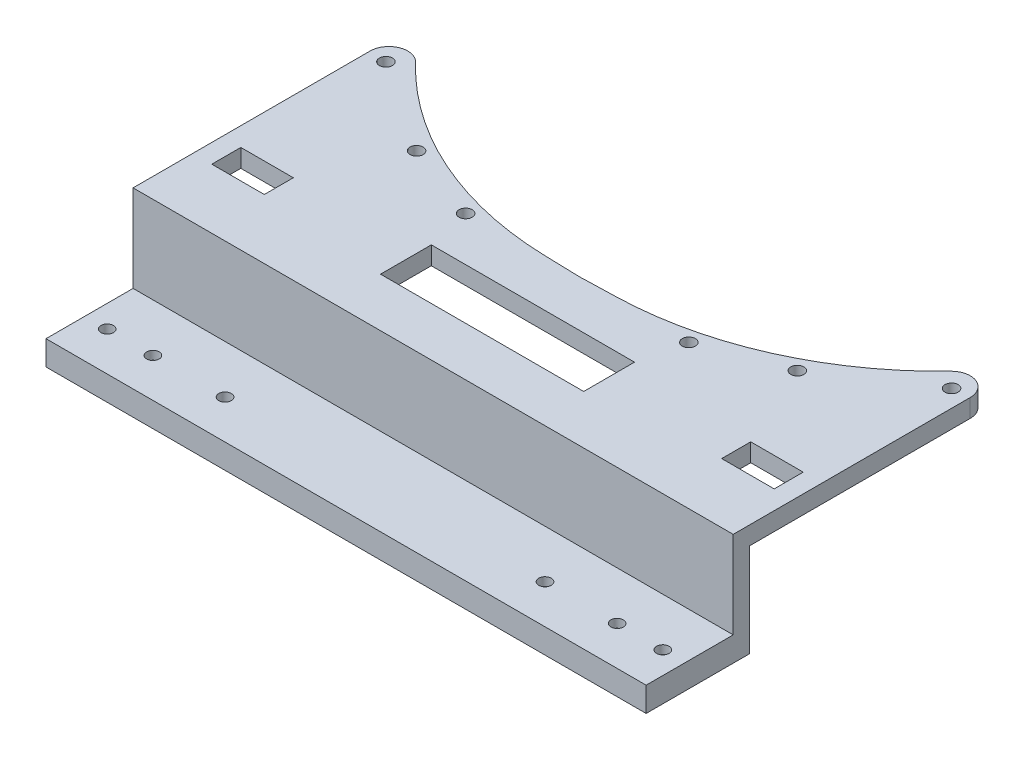
from build123d import *

# Parameters (mm, degrees)
BOSS_EXTRUDE2_DEPTH = 14.285
SKETCH4_W           = 105.034
SKETCH4_H           = 3.81
BOSS_EXTRUDE3_DEPTH = 19.533
SKETCH5_W           = 15.24
SKETCH5_H           = 15.24
CUT_EXTRUDE1_DEPTH  = 105.034
BOSS_EXTRUDE7_START = -3.175
BOSS_EXTRUDE7_DEPTH = 3.175
CUT_EXTRUDE2_REACH  = 21.533
SKETCH9_R           = 1.15
SKETCH9_W           = 35.56
SKETCH9_H           = 8.89
SKETCH9_W_2         = 9.19
SKETCH9_H_2         = 5.08
CUT_EXTRUDE3_REACH  = 6.293
SKETCH13_R          = 1.0922


with BuildPart() as part:
    # Sketch1 → Boss-Extrude2 (new body)
    with BuildSketch(Plane.XY):
        Polygon((13.381, 0.381), (-0.381, 0.381), (-0.381, -1.397), (0.4572, -1.397), (0.4572, -2.413), (-1.397, -2.413), (-1.397, 1.397), (-1.397, 17.12), (103.637, 17.12), (103.637, 1.397), (103.637, -2.413), (101.7828, -2.413), (101.7828, -1.397), (102.621, -1.397), (102.621, 0.381), (88.859, 0.381), (88.859, -1.397), (89.621, -1.397), (89.621, -2.413), (87.843, -2.413), (83.017, -2.413), (81.1628, -2.413), (81.1628, -1.397), (82.001, -1.397), (82.001, 0.381), (20.239, 0.381), (20.239, -1.397), (21.0772, -1.397), (21.0772, -2.413), (19.223, -2.413), (14.397, -2.413), (12.619, -2.413), (12.619, -1.397), (13.381, -1.397), align=None)
    extrude(amount=-BOSS_EXTRUDE2_DEPTH)

    # Sketch4 → Boss-Extrude3 (add)
    with BuildSketch(Plane(origin=(0, 17.12, 0), x_dir=(1, 0, 0), z_dir=(0, 1, 0))):
        with Locations((51.12, -1.905)):
            Rectangle(SKETCH4_W, SKETCH4_H)
    extrude(amount=-BOSS_EXTRUDE3_DEPTH)

    # Sketch5 → Cut-Extrude1 (cut)
    with BuildSketch(Plane(origin=(103.637, 0, 0), x_dir=(0, 0, -1), z_dir=(1, 0, 0))):
        with Locations((3.81, 9.5)):
            Rectangle(SKETCH5_W, SKETCH5_H)
    extrude(amount=-CUT_EXTRUDE1_DEPTH, mode=Mode.SUBTRACT)

    # Sketch8 → Boss-Extrude7 (add)
    with BuildSketch(Plane(origin=(0, 17.12, 0), x_dir=(1, 0, 0), z_dir=(0, 1, 0)).offset(BOSS_EXTRUDE7_START)):
        with BuildLine():
            Line((-1.397, 52.90899931), (-1.397, 14.285))
            Line((-1.397, 14.285), (103.637, 14.285))
            Line((103.637, 14.285), (103.637, 52.90899931))
            ThreePointArc((103.637, 52.90899931), (101.565258526, 55.97325582), (97.949738971, 55.192359514))
            ThreePointArc((97.949738971, 55.192359514), (79.465238701, 42.200806947), (57.433563247, 37.194564339))
            Line((57.433563247, 37.194564339), (51.12, 37.012430992))
            Line((51.12, 37.012430992), (44.806436753, 37.194564339))
            ThreePointArc((44.806436753, 37.194564339), (22.774761299, 42.200806947), (4.290261029, 55.192359514))
            ThreePointArc((4.290261029, 55.192359514), (0.674741474, 55.97325582), (-1.397, 52.90899931))
        make_face()
    extrude(amount=BOSS_EXTRUDE7_DEPTH)

    # Sketch9 → Cut-Extrude2 (cut, up to next)
    with BuildSketch(Plane(origin=(0, 17.12, 0), x_dir=(1, 0, 0), z_dir=(0, 1, 0)), mode=Mode.PRIVATE) as cut_extrude2_sk1:
        with Locations((100.617474683, 52.660280557)):
            Circle(SKETCH9_R)
    cut_extrude2_tool1 = extrude(cut_extrude2_sk1.sketch, amount=-CUT_EXTRUDE2_REACH, mode=Mode.PRIVATE) & part.part
    add(cut_extrude2_tool1.solids().sort_by_distance((100.617475, 17.12, -52.660281))[0], mode=Mode.SUBTRACT)
    # Sketch9 → Cut-Extrude2 (cut, up to next)
    with BuildSketch(Plane(origin=(0, 17.12, 0), x_dir=(1, 0, 0), z_dir=(0, 1, 0)), mode=Mode.PRIVATE) as cut_extrude2_sk2:
        with Locations((84.44065509, 41.851275276)):
            Circle(SKETCH9_R)
    cut_extrude2_tool2 = extrude(cut_extrude2_sk2.sketch, amount=-CUT_EXTRUDE2_REACH, mode=Mode.PRIVATE) & part.part
    add(cut_extrude2_tool2.solids().sort_by_distance((84.440655, 17.12, -41.851275))[0], mode=Mode.SUBTRACT)
    # Sketch9 → Cut-Extrude2 (cut, up to next)
    with BuildSketch(Plane(origin=(0, 17.12, 0), x_dir=(1, 0, 0), z_dir=(0, 1, 0)), mode=Mode.PRIVATE) as cut_extrude2_sk3:
        with Locations((70.655700553, 36.645378632)):
            Circle(SKETCH9_R)
    cut_extrude2_tool3 = extrude(cut_extrude2_sk3.sketch, amount=-CUT_EXTRUDE2_REACH, mode=Mode.PRIVATE) & part.part
    add(cut_extrude2_tool3.solids().sort_by_distance((70.655701, 17.12, -36.645379))[0], mode=Mode.SUBTRACT)
    # Sketch9 → Cut-Extrude2 (cut, up to next)
    with BuildSketch(Plane(origin=(0, 17.12, 0), x_dir=(1, 0, 0), z_dir=(0, 1, 0)), mode=Mode.PRIVATE) as cut_extrude2_sk4:
        with Locations((31.584299447, 36.645378632)):
            Circle(SKETCH9_R)
    cut_extrude2_tool4 = extrude(cut_extrude2_sk4.sketch, amount=-CUT_EXTRUDE2_REACH, mode=Mode.PRIVATE) & part.part
    add(cut_extrude2_tool4.solids().sort_by_distance((31.584299, 17.12, -36.645379))[0], mode=Mode.SUBTRACT)
    # Sketch9 → Cut-Extrude2 (cut, up to next)
    with BuildSketch(Plane(origin=(0, 17.12, 0), x_dir=(1, 0, 0), z_dir=(0, 1, 0)), mode=Mode.PRIVATE) as cut_extrude2_sk5:
        with Locations((17.79934491, 41.851275276)):
            Circle(SKETCH9_R)
    cut_extrude2_tool5 = extrude(cut_extrude2_sk5.sketch, amount=-CUT_EXTRUDE2_REACH, mode=Mode.PRIVATE) & part.part
    add(cut_extrude2_tool5.solids().sort_by_distance((17.799345, 17.12, -41.851275))[0], mode=Mode.SUBTRACT)
    # Sketch9 → Cut-Extrude2 (cut, up to next)
    with BuildSketch(Plane(origin=(0, 17.12, 0), x_dir=(1, 0, 0), z_dir=(0, 1, 0)), mode=Mode.PRIVATE) as cut_extrude2_sk6:
        with Locations((1.622525317, 52.660280557)):
            Circle(SKETCH9_R)
    cut_extrude2_tool6 = extrude(cut_extrude2_sk6.sketch, amount=-CUT_EXTRUDE2_REACH, mode=Mode.PRIVATE) & part.part
    add(cut_extrude2_tool6.solids().sort_by_distance((1.622525, 17.12, -52.660281))[0], mode=Mode.SUBTRACT)
    # Sketch9 → Cut-Extrude2 (cut, up to next)
    with BuildSketch(Plane(origin=(0, 17.12, 0), x_dir=(1, 0, 0), z_dir=(0, 1, 0)), mode=Mode.PRIVATE) as cut_extrude2_sk7:
        with Locations((51.1199898, 24.445)):
            Rectangle(SKETCH9_W, SKETCH9_H)
    cut_extrude2_tool7 = extrude(cut_extrude2_sk7.sketch, amount=-CUT_EXTRUDE2_REACH, mode=Mode.PRIVATE) & part.part
    add(cut_extrude2_tool7.solids().sort_by_distance((51.11999, 17.12, -24.445))[0], mode=Mode.SUBTRACT)
    # Sketch9 → Cut-Extrude2 (cut, up to next)
    with BuildSketch(Plane(origin=(0, 17.12, 0), x_dir=(1, 0, 0), z_dir=(0, 1, 0)), mode=Mode.PRIVATE) as cut_extrude2_sk8:
        with Locations((6.5, 24.445)):
            Rectangle(SKETCH9_W_2, SKETCH9_H_2)
    cut_extrude2_tool8 = extrude(cut_extrude2_sk8.sketch, amount=-CUT_EXTRUDE2_REACH, mode=Mode.PRIVATE) & part.part
    add(cut_extrude2_tool8.solids().sort_by_distance((6.5, 17.12, -24.445))[0], mode=Mode.SUBTRACT)
    # Sketch9 → Cut-Extrude2 (cut, up to next)
    with BuildSketch(Plane(origin=(0, 17.12, 0), x_dir=(1, 0, 0), z_dir=(0, 1, 0)), mode=Mode.PRIVATE) as cut_extrude2_sk9:
        with Locations((95.74, 24.445)):
            Rectangle(SKETCH9_W_2, SKETCH9_H_2)
    cut_extrude2_tool9 = extrude(cut_extrude2_sk9.sketch, amount=-CUT_EXTRUDE2_REACH, mode=Mode.PRIVATE) & part.part
    add(cut_extrude2_tool9.solids().sort_by_distance((95.74, 17.12, -24.445))[0], mode=Mode.SUBTRACT)

    # Sketch13 → Cut-Extrude3 (cut, up to next)
    with BuildSketch(Plane(origin=(0, 1.88, 0), x_dir=(1, 0, 0), z_dir=(0, 1, 0)), mode=Mode.PRIVATE) as cut_extrude3_sk1:
        with Locations((23.12, 3.008)):
            Circle(SKETCH13_R)
    cut_extrude3_tool1 = extrude(cut_extrude3_sk1.sketch, amount=-CUT_EXTRUDE3_REACH, mode=Mode.PRIVATE) & part.part
    add(cut_extrude3_tool1.solids().sort_by_distance((23.12, 1.88, -3.008))[0], mode=Mode.SUBTRACT)
    # Sketch13 → Cut-Extrude3 (cut, up to next)
    with BuildSketch(Plane(origin=(0, 1.88, 0), x_dir=(1, 0, 0), z_dir=(0, 1, 0)), mode=Mode.PRIVATE) as cut_extrude3_sk2:
        with Locations((10.5, 3.008)):
            Circle(SKETCH13_R)
    cut_extrude3_tool2 = extrude(cut_extrude3_sk2.sketch, amount=-CUT_EXTRUDE3_REACH, mode=Mode.PRIVATE) & part.part
    add(cut_extrude3_tool2.solids().sort_by_distance((10.5, 1.88, -3.008))[0], mode=Mode.SUBTRACT)
    # Sketch13 → Cut-Extrude3 (cut, up to next)
    with BuildSketch(Plane(origin=(0, 1.88, 0), x_dir=(1, 0, 0), z_dir=(0, 1, 0)), mode=Mode.PRIVATE) as cut_extrude3_sk3:
        with Locations((2.5, 3.008)):
            Circle(SKETCH13_R)
    cut_extrude3_tool3 = extrude(cut_extrude3_sk3.sketch, amount=-CUT_EXTRUDE3_REACH, mode=Mode.PRIVATE) & part.part
    add(cut_extrude3_tool3.solids().sort_by_distance((2.5, 1.88, -3.008))[0], mode=Mode.SUBTRACT)
    # Sketch13 → Cut-Extrude3 (cut, up to next)
    with BuildSketch(Plane(origin=(0, 1.88, 0), x_dir=(1, 0, 0), z_dir=(0, 1, 0)), mode=Mode.PRIVATE) as cut_extrude3_sk4:
        with Locations((79.12, 3.008)):
            Circle(SKETCH13_R)
    cut_extrude3_tool4 = extrude(cut_extrude3_sk4.sketch, amount=-CUT_EXTRUDE3_REACH, mode=Mode.PRIVATE) & part.part
    add(cut_extrude3_tool4.solids().sort_by_distance((79.12, 1.88, -3.008))[0], mode=Mode.SUBTRACT)
    # Sketch13 → Cut-Extrude3 (cut, up to next)
    with BuildSketch(Plane(origin=(0, 1.88, 0), x_dir=(1, 0, 0), z_dir=(0, 1, 0)), mode=Mode.PRIVATE) as cut_extrude3_sk5:
        with Locations((91.74, 3.008)):
            Circle(SKETCH13_R)
    cut_extrude3_tool5 = extrude(cut_extrude3_sk5.sketch, amount=-CUT_EXTRUDE3_REACH, mode=Mode.PRIVATE) & part.part
    add(cut_extrude3_tool5.solids().sort_by_distance((91.74, 1.88, -3.008))[0], mode=Mode.SUBTRACT)
    # Sketch13 → Cut-Extrude3 (cut, up to next)
    with BuildSketch(Plane(origin=(0, 1.88, 0), x_dir=(1, 0, 0), z_dir=(0, 1, 0)), mode=Mode.PRIVATE) as cut_extrude3_sk6:
        with Locations((99.74, 3.008)):
            Circle(SKETCH13_R)
    cut_extrude3_tool6 = extrude(cut_extrude3_sk6.sketch, amount=-CUT_EXTRUDE3_REACH, mode=Mode.PRIVATE) & part.part
    add(cut_extrude3_tool6.solids().sort_by_distance((99.74, 1.88, -3.008))[0], mode=Mode.SUBTRACT)


solid = part.part
